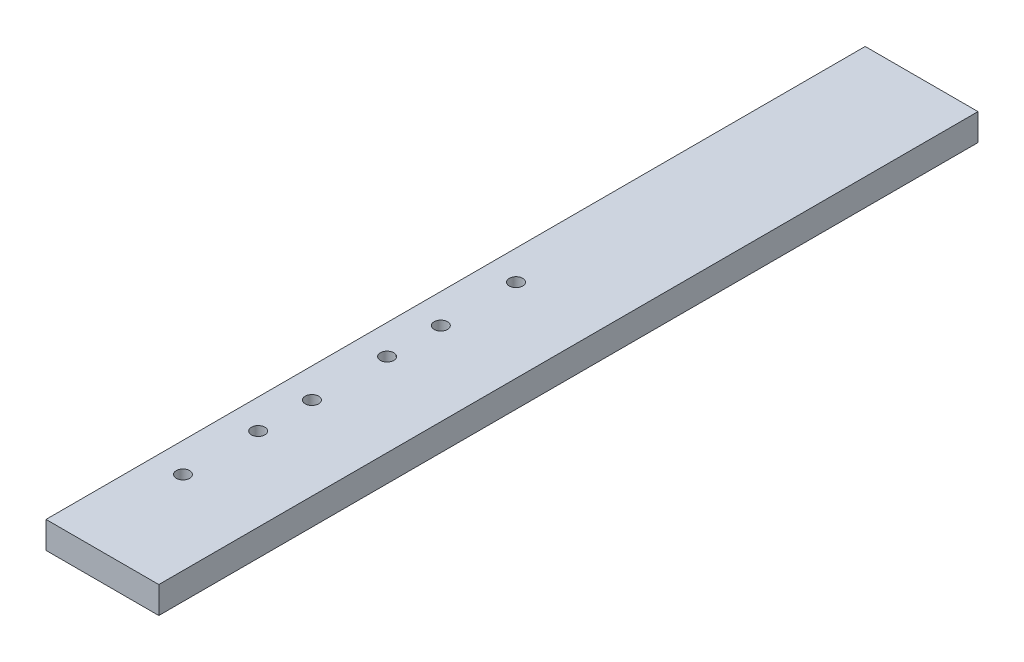
from build123d import *

# Parameters (mm, degrees)
SKETCH1_W           = 26.67
SKETCH1_H           = 193.675
BOSS_EXTRUDE1_DEPTH = 6.35
SKETCH3_R           = 1.5875
CUT_EXTRUDE1_DEPTH  = 7.35


with BuildPart() as part:
    # Sketch1 → Boss-Extrude1 (new body)
    with BuildSketch(Plane(origin=(0, 0, 0), x_dir=(1, 0, 0), z_dir=(0, 1, 0))):
        with Locations((13.335, 96.8375)):
            Rectangle(SKETCH1_W, SKETCH1_H)
    extrude(amount=BOSS_EXTRUDE1_DEPTH)

    # Sketch3 → Cut-Extrude1 (cut, through all)
    with BuildSketch(Plane(origin=(0, 6.35, 0), x_dir=(1, 0, 0), z_dir=(0, 1, 0))):
        with Locations((6.985, 25.4)):
            Circle(SKETCH3_R)
        with Locations((6.985, 43.18)):
            Circle(SKETCH3_R)
        with Locations((6.985, 73.66)):
            Circle(SKETCH3_R)
        with Locations((6.985, 55.88)):
            Circle(SKETCH3_R)
        with Locations((6.985, 104.14)):
            Circle(SKETCH3_R)
        with Locations((6.985, 86.36)):
            Circle(SKETCH3_R)
    extrude(amount=-CUT_EXTRUDE1_DEPTH, mode=Mode.SUBTRACT)


solid = part.part
